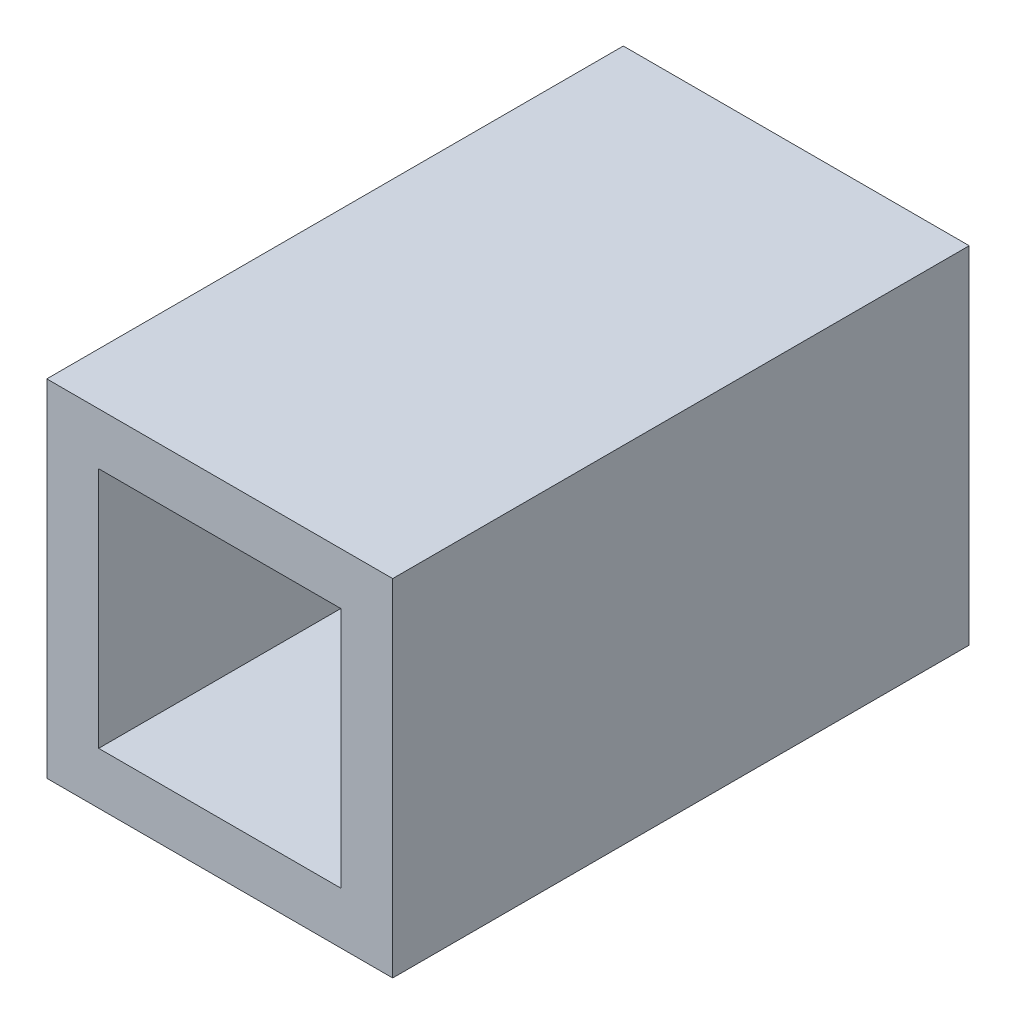
from build123d import *

# Parameters (mm, degrees)
SKETCH1_W           = 6
SKETCH1_H           = 6
SKETCH1_W_2         = 4.2
SKETCH1_H_2         = 4.2
BOSS_EXTRUDE1_DEPTH = 10


with BuildPart() as part:
    # Sketch1 → Boss-Extrude1 (new body)
    with BuildSketch(Plane.XY):
        with Locations((2.1, 2.1)):
            Rectangle(SKETCH1_W, SKETCH1_H)
        with Locations((2.1, 2.1)):
            Rectangle(SKETCH1_W_2, SKETCH1_H_2, mode=Mode.SUBTRACT)
    extrude(amount=BOSS_EXTRUDE1_DEPTH)


solid = part.part
